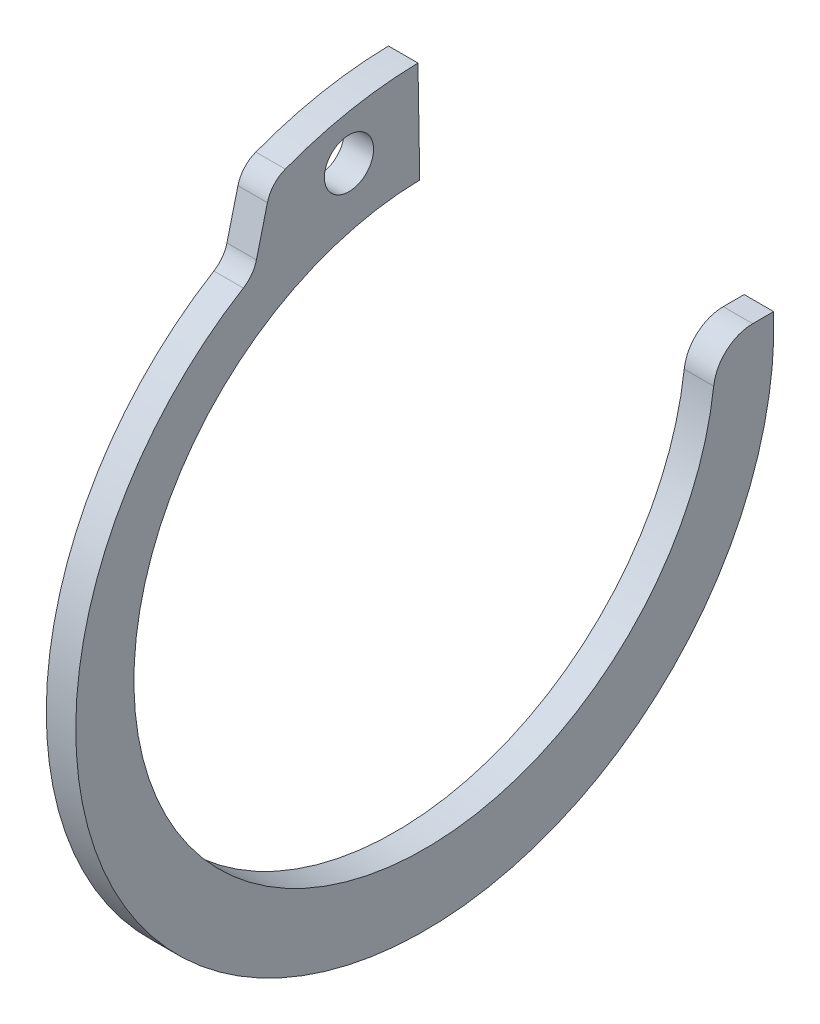
from build123d import *

# Parameters (mm, degrees)
SKETCH1_R          = 1.25
EXTRUDE1_DEPTH     = 0.75
FILLET1_R          = 1.48
CUT_EXTRUDE1_DEPTH = 2.5
FILLET2_R          = 2


with BuildPart() as part:
    # Sketch1 → Extrude1 (new body, symmetric)
    with BuildSketch(Plane(origin=(0, 0, 0), x_dir=(0, 0, -1), z_dir=(1, 0, 0))):
        with BuildLine():
            Line((-0.258295615, 14.797745888), (-0.349048129, 19.996953903))
            ThreePointArc((-0.349048129, 19.996953903), (-4.163801356, 19.561767769), (-7.825100504, 18.40564593))
            Line((-7.825100504, 18.40564593), (-8.717280741, 14.827306447))
            ThreePointArc((-8.717280741, 14.827306447), (0, -18.4), (8.717280741, 14.827306447))
            Line((8.717280741, 14.827306447), (7.825100504, 18.40564593))
            ThreePointArc((7.825100504, 18.40564593), (4.163801356, 19.561767769), (0.349048129, 19.996953903))
            Line((0.349048129, 19.996953903), (0.258295615, 14.797745888))
            ThreePointArc((0.258295615, 14.797745888), (0, -14.8), (-0.258295615, 14.797745888))
        make_face()
        with Locations((-3.85879125, 17.335295056)):
            Circle(SKETCH1_R, mode=Mode.SUBTRACT)
        with Locations((3.85879125, 17.335295056)):
            Circle(SKETCH1_R, mode=Mode.SUBTRACT)
    extrude(amount=EXTRUDE1_DEPTH, both=True)

    # Fillet1
    fillet1_edges = [part.edges().sort_by_distance(p)[0] for p in [
        (0, 18.40564593, -7.825100504),
        (0, 14.827306447, -8.717280741),
        (0, 14.827306447, 8.717280741),
        (0, 18.40564593, 7.825100504),
    ]]
    fillet(fillet1_edges, radius=FILLET1_R)

    # Sketch3 → Cut-Extrude1 (cut, through all)
    with BuildSketch(Plane(origin=(0.75, 0, 0), x_dir=(0, 0, -1), z_dir=(1, 0, 0))):
        Polygon((0, 0), (0, 37.659404293), (33.944851403, 0), align=None)
    extrude(amount=-CUT_EXTRUDE1_DEPTH, mode=Mode.SUBTRACT)

    # Fillet2
    fillet2_edges = [part.edges().sort_by_distance(p)[0] for p in [
        (0, 0, -14.8),
    ]]
    fillet(fillet2_edges, radius=FILLET2_R)


solid = part.part
